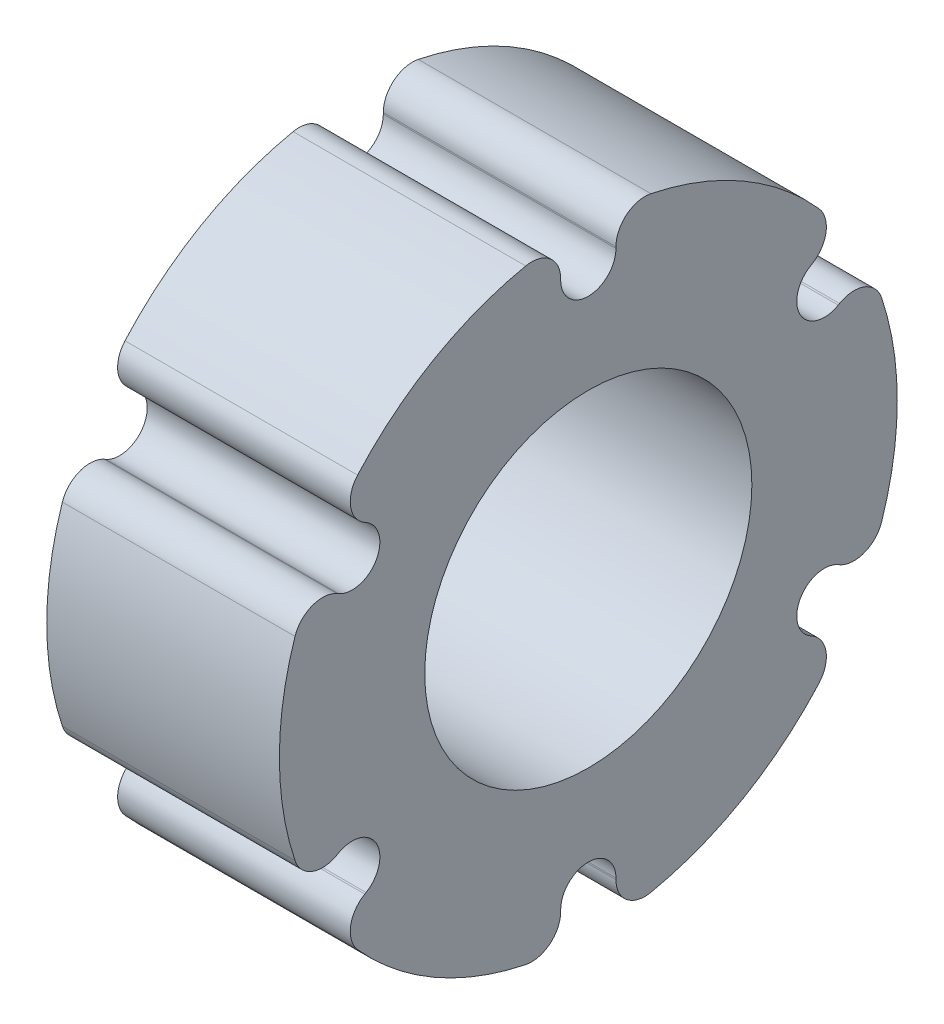
from build123d import *

# Parameters (mm, degrees)
SKETCH1_R           = 14.2875
BOSS_EXTRUDE1_DEPTH = 20.32


with BuildPart() as part:
    # Sketch1 → Boss-Extrude1 (new body)
    with BuildSketch(Plane(origin=(0, 0, 0), x_dir=(0, 0, -1), z_dir=(1, 0, 0))):
        with BuildLine():
            Line((-2.413, 23.8125), (-2.413, 23.940510589))
            ThreePointArc((-2.413, 23.940510589), (-3.349172921, 25.91011428), (-5.467597403, 26.427836364))
            ThreePointArc((-5.467597403, 26.427836364), (-13.49375, 23.371860585), (-20.153378957, 17.94899643))
            ThreePointArc((-20.153378957, 17.94899643), (-20.764230721, 15.855525972), (-19.526590349, 14.059974594))
            Line((-19.526590349, 14.059974594), (-19.415729928, 13.995969299))
            ThreePointArc((-19.415729928, 13.995969299), (-18.532510628, 10.69975), (-21.828729928, 9.816530701))
            Line((-21.828729928, 9.816530701), (-21.939590349, 9.880535995))
            ThreePointArc((-21.939590349, 9.880535995), (-24.113403642, 10.054588309), (-25.62097636, 8.478839934))
            ThreePointArc((-25.62097636, 8.478839934), (-26.9875, 0), (-25.62097636, -8.478839934))
            ThreePointArc((-25.62097636, -8.478839934), (-24.113403642, -10.054588309), (-21.939590349, -9.880535995))
            Line((-21.939590349, -9.880535995), (-21.828729928, -9.816530701))
            ThreePointArc((-21.828729928, -9.816530701), (-18.532510628, -10.69975), (-19.415729928, -13.995969299))
            Line((-19.415729928, -13.995969299), (-19.526590349, -14.059974594))
            ThreePointArc((-19.526590349, -14.059974594), (-20.764230721, -15.855525972), (-20.153378957, -17.94899643))
            ThreePointArc((-20.153378957, -17.94899643), (-13.49375, -23.371860585), (-5.467597403, -26.427836364))
            ThreePointArc((-5.467597403, -26.427836364), (-3.349172921, -25.91011428), (-2.413, -23.940510589))
            Line((-2.413, -23.940510589), (-2.413, -23.8125))
            ThreePointArc((-2.413, -23.8125), (0, -21.3995), (2.413, -23.8125))
            Line((2.413, -23.8125), (2.413, -23.940510589))
            ThreePointArc((2.413, -23.940510589), (3.349172921, -25.91011428), (5.467597403, -26.427836364))
            ThreePointArc((5.467597403, -26.427836364), (13.49375, -23.371860585), (20.153378957, -17.94899643))
            ThreePointArc((20.153378957, -17.94899643), (20.764230721, -15.855525972), (19.526590349, -14.059974594))
            Line((19.526590349, -14.059974594), (19.415729928, -13.995969299))
            ThreePointArc((19.415729928, -13.995969299), (18.532510628, -10.69975), (21.828729928, -9.816530701))
            Line((21.828729928, -9.816530701), (21.939590349, -9.880535995))
            ThreePointArc((21.939590349, -9.880535995), (24.113403642, -10.054588309), (25.62097636, -8.478839934))
            ThreePointArc((25.62097636, -8.478839934), (26.9875, 0), (25.62097636, 8.478839934))
            ThreePointArc((25.62097636, 8.478839934), (24.113403642, 10.054588309), (21.939590349, 9.880535995))
            Line((21.939590349, 9.880535995), (21.828729928, 9.816530701))
            ThreePointArc((21.828729928, 9.816530701), (18.532510628, 10.69975), (19.415729928, 13.995969299))
            Line((19.415729928, 13.995969299), (19.526590349, 14.059974594))
            ThreePointArc((19.526590349, 14.059974594), (20.764230721, 15.855525972), (20.153378957, 17.94899643))
            ThreePointArc((20.153378957, 17.94899643), (13.49375, 23.371860585), (5.467597403, 26.427836364))
            ThreePointArc((5.467597403, 26.427836364), (3.349172921, 25.91011428), (2.413, 23.940510589))
            Line((2.413, 23.940510589), (2.413, 23.8125))
            ThreePointArc((2.413, 23.8125), (0, 21.3995), (-2.413, 23.8125))
        make_face()
        Circle(SKETCH1_R, mode=Mode.SUBTRACT)
    extrude(amount=BOSS_EXTRUDE1_DEPTH)


solid = part.part
